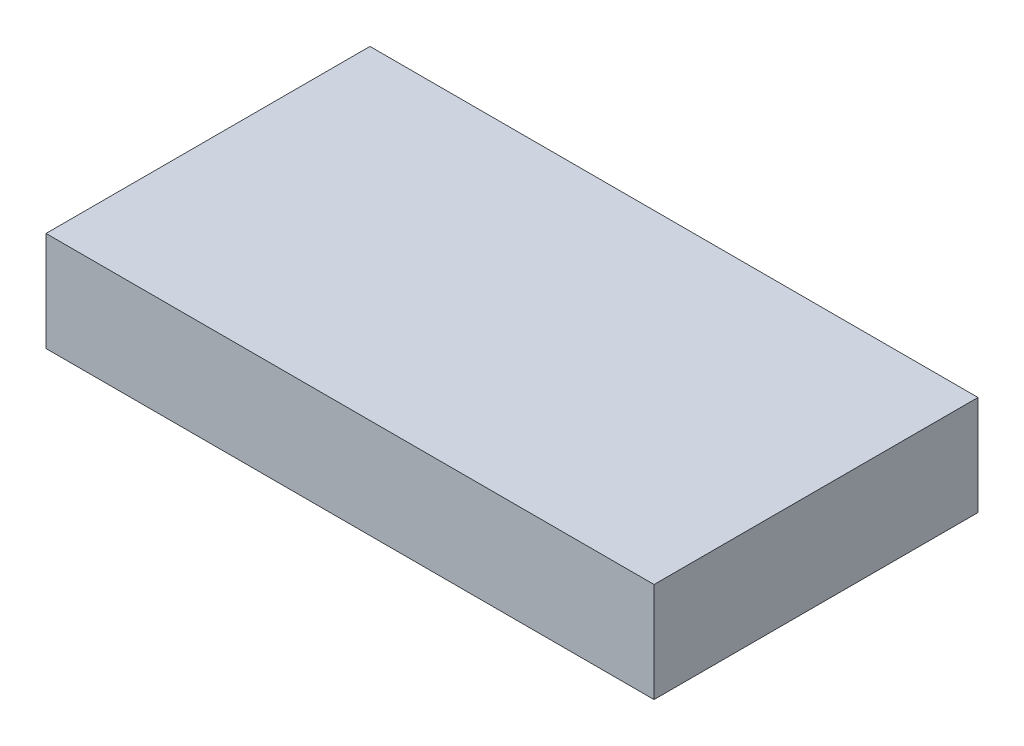
from build123d import *

# Parameters (mm, degrees)
SKETCH1_W           = 12.2
SKETCH1_H           = 6.5
BOSS_EXTRUDE1_DEPTH = 2


with BuildPart() as part:
    # Sketch1 → Boss-Extrude1 (new body)
    with BuildSketch(Plane(origin=(0, 0, 0), x_dir=(1, 0, 0), z_dir=(0, 1, 0))):
        with Locations((6.1, 2.75)):
            Rectangle(SKETCH1_W, SKETCH1_H)
    extrude(amount=BOSS_EXTRUDE1_DEPTH)


solid = part.part
